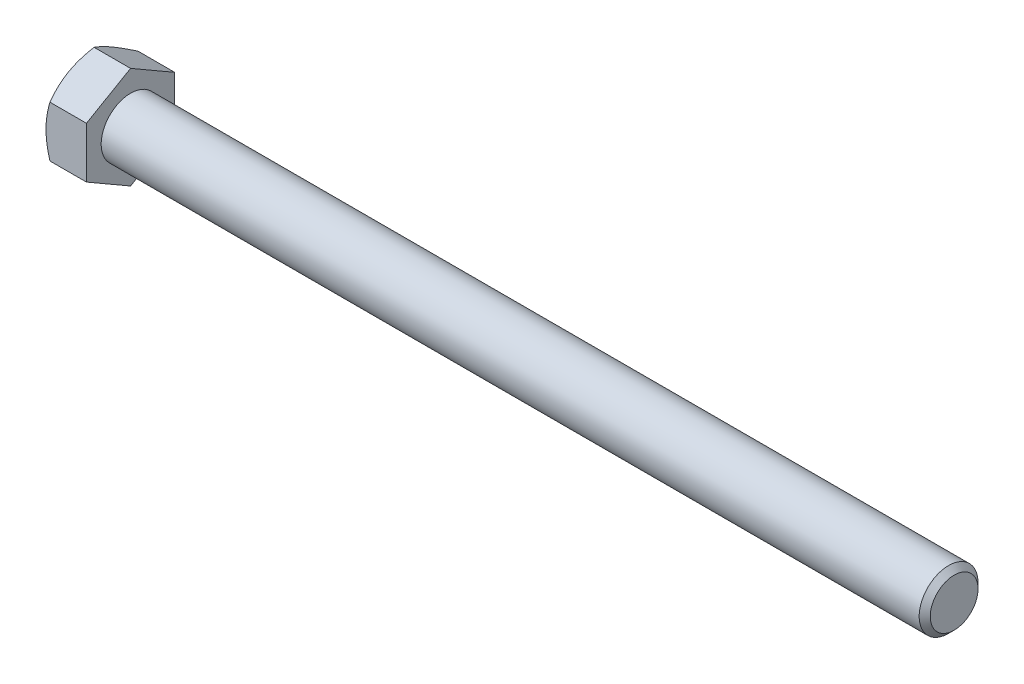
from build123d import *

# Parameters (mm, degrees)
SKETCH5_R           = 6.35
BOSS_EXTRUDE3_DEPTH = 177.8
CHAMFER1_SIZE       = 1.195753846
BOSS_EXTRUDE4_DEPTH = 8.73125
SKETCH8_OUTSIDE_W   = 708.434
SKETCH8_OUTSIDE_H   = 711.382
SKETCH8_OUTSIDE_R   = 9.525
CUT_EXTRUDE3_DEPTH  = 187.53125
CUT_EXTRUDE3_TAPER  = 60
CUT_EXTRUDE4_DEPTH  = 0.254
CIRPATTERN1_COUNT   = 3


with BuildPart() as part:
    # Sketch5 → Boss-Extrude3 (new body)
    with BuildSketch(Plane(origin=(93.265625, 0, 0), x_dir=(0, 0, -1), z_dir=(1, 0, 0))):
        Circle(SKETCH5_R)
    extrude(amount=-BOSS_EXTRUDE3_DEPTH)

    # Chamfer1
    chamfer1_edges = [part.edges().sort_by_distance(p)[0] for p in [
        (93.265625, 0, 6.35),
    ]]
    chamfer(chamfer1_edges, length=CHAMFER1_SIZE)

    # Sketch6 → Boss-Extrude4 (add)
    with BuildSketch(Plane.ZY.offset(84.534375)):
        Polygon((9.525, 5.499261314), (0, 10.998522628), (-9.525, 5.499261314), (-9.525, -5.499261314), (0, -10.998522628), (9.525, -5.499261314), align=None)
    extrude(amount=BOSS_EXTRUDE4_DEPTH)

    # Sketch8 outside → Cut-Extrude3 (cut, through all)
    with BuildSketch(Plane.ZY.offset(93.265625)):
        Rectangle(SKETCH8_OUTSIDE_W, SKETCH8_OUTSIDE_H)
        Circle(SKETCH8_OUTSIDE_R, mode=Mode.SUBTRACT)
    extrude(amount=-CUT_EXTRUDE3_DEPTH, taper=CUT_EXTRUDE3_TAPER, mode=Mode.SUBTRACT)

    # Sketch12 → Cut-Extrude4 (cut)
    with BuildSketch(Plane.ZY.offset(93.265625)):
        with BuildLine():
            Line((0.28575, 7.33425), (0.28575, 4.09575))
            ThreePointArc((0.28575, 4.09575), (0, 3.81), (-0.28575, 4.09575))
            Line((-0.28575, 4.09575), (-0.28575, 7.33425))
            ThreePointArc((-0.28575, 7.33425), (0, 7.62), (0.28575, 7.33425))
        make_face()
    cut_extrude4 = extrude(amount=-CUT_EXTRUDE4_DEPTH, mode=Mode.SUBTRACT)

    # CirPattern1: Cut-Extrude4 ×3 about axis
    cirpattern1_axis = Axis((0, 0, 0), (1, 0, 0))
    for i in range(1, CIRPATTERN1_COUNT):
        add(cut_extrude4.rotate(cirpattern1_axis, i * 360 / CIRPATTERN1_COUNT), mode=Mode.SUBTRACT)


solid = part.part
